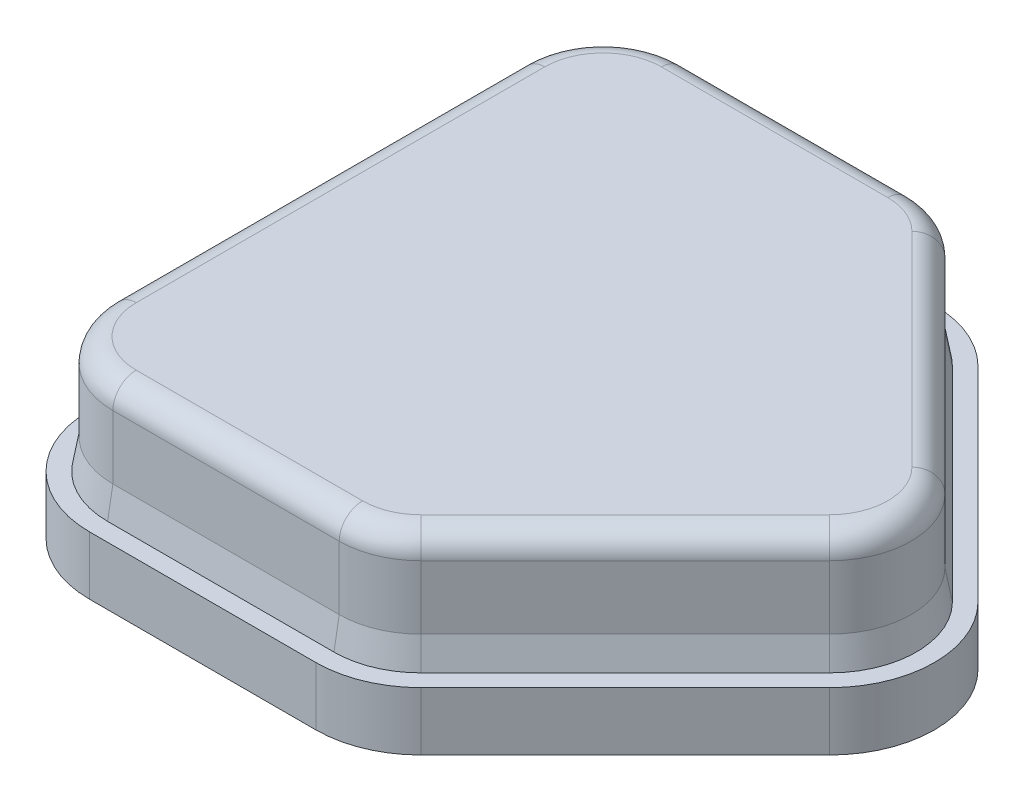
from build123d import *

# Parameters (mm, degrees)
EXTRUDE_3_DEPTH     = 1
EXTRUDE_4_DEPTH     = 2
CHAMFER_1_SIZE      = 0.09
CHAMFER_1_SIZE2     = 0.510415364
FILLET_3_R          = 0.4
SKETCH_8_R          = 1.65
CUT_EXTRUDE_1_DEPTH = 1.65


with BuildPart() as part:
    # 草图5 → 凸台-拉伸3 (new body)
    with BuildSketch(Plane(origin=(0, 0, 0), x_dir=(1, 0, 0), z_dir=(0, 1, 0))):
        with BuildLine():
            Line((-4.5, -5.3), (-0.621320344, -5.3))
            ThreePointArc((-0.621320344, -5.3), (0.067509835, -5.162983159), (0.651471863, -4.772792206))
            Line((0.651471863, -4.772792206), (4.151471863, -1.272792206))
            ThreePointArc((4.151471863, -1.272792206), (4.678679656, 0), (4.151471863, 1.272792206))
            Line((4.151471863, 1.272792206), (0.651471863, 4.772792206))
            ThreePointArc((0.651471863, 4.772792206), (0.067509835, 5.162983159), (-0.621320344, 5.3))
            Line((-0.621320344, 5.3), (-4.5, 5.3))
            ThreePointArc((-4.5, 5.3), (-5.772792206, 4.772792206), (-6.3, 3.5))
            Line((-6.3, 3.5), (-6.3, -3.5))
            ThreePointArc((-6.3, -3.5), (-5.772792206, -4.772792206), (-4.5, -5.3))
        make_face()
    extrude(amount=EXTRUDE_3_DEPTH)

    # 草图6 → 凸台-拉伸4 (add)
    with BuildSketch(Plane(origin=(0, 1, 0), x_dir=(1, 0, 0), z_dir=(0, 1, 0))):
        with BuildLine():
            Line((-4.5, -4.9), (-0.621320344, -4.9))
            ThreePointArc((-0.621320344, -4.9), (-0.085563538, -4.793431346), (0.36862915, -4.489949494))
            Line((0.36862915, -4.489949494), (3.86862915, -0.989949494))
            ThreePointArc((3.86862915, -0.989949494), (4.278679656, 0), (3.86862915, 0.989949494))
            Line((3.86862915, 0.989949494), (0.36862915, 4.489949494))
            ThreePointArc((0.36862915, 4.489949494), (-0.085563538, 4.793431346), (-0.621320344, 4.9))
            Line((-0.621320344, 4.9), (-4.5, 4.9))
            ThreePointArc((-4.5, 4.9), (-5.489949494, 4.489949494), (-5.9, 3.5))
            Line((-5.9, 3.5), (-5.9, -3.5))
            ThreePointArc((-5.9, -3.5), (-5.489949494, -4.489949494), (-4.5, -4.9))
        make_face()
    extrude(amount=EXTRUDE_4_DEPTH)

    # 倒角1
    chamfer_1_edges = [part.edges().sort_by_distance(p)[0] for p in [
        (-5.489949494, 1, 4.489949494),
        (-2.560660172, 1, 4.9),
        (-0.085563538, 1, 4.793431346),
        (2.11862915, 1, 2.739949494),
        (4.278679656, 1, 0),
        (2.11862915, 1, -2.739949494),
        (-0.085563538, 1, -4.793431346),
        (-2.560660172, 1, -4.9),
        (-5.489949494, 1, -4.489949494),
        (-5.9, 1, 0),
    ]]
    chamfer_1_side = [part.faces().sort_by_distance(p)[0] for p in [
        (-2.560660172, 1, 5.1473922),
    ]]
    chamfer(chamfer_1_edges, length=CHAMFER_1_SIZE, length2=CHAMFER_1_SIZE2, reference=chamfer_1_side[0])

    # 圆角3
    fillet_3_edges = [part.edges().sort_by_distance(p)[0] for p in [
        (-5.489949494, 3, 4.489949494),
        (-2.560660172, 3, 4.9),
        (-0.085563538, 3, 4.793431346),
        (2.11862915, 3, 2.739949494),
        (4.278679656, 3, 0),
        (2.11862915, 3, -2.739949494),
        (-0.085563538, 3, -4.793431346),
        (-2.560660172, 3, -4.9),
        (-5.489949494, 3, -4.489949494),
        (-5.9, 3, 0),
    ]]
    fillet(fillet_3_edges, radius=FILLET_3_R)

    # 草图8 → 切除-拉伸1 (cut)
    with BuildSketch(Plane.XZ):
        with Locations((-1.6, 0)):
            Circle(SKETCH_8_R)
    extrude(amount=-CUT_EXTRUDE_1_DEPTH, mode=Mode.SUBTRACT)


solid = part.part
